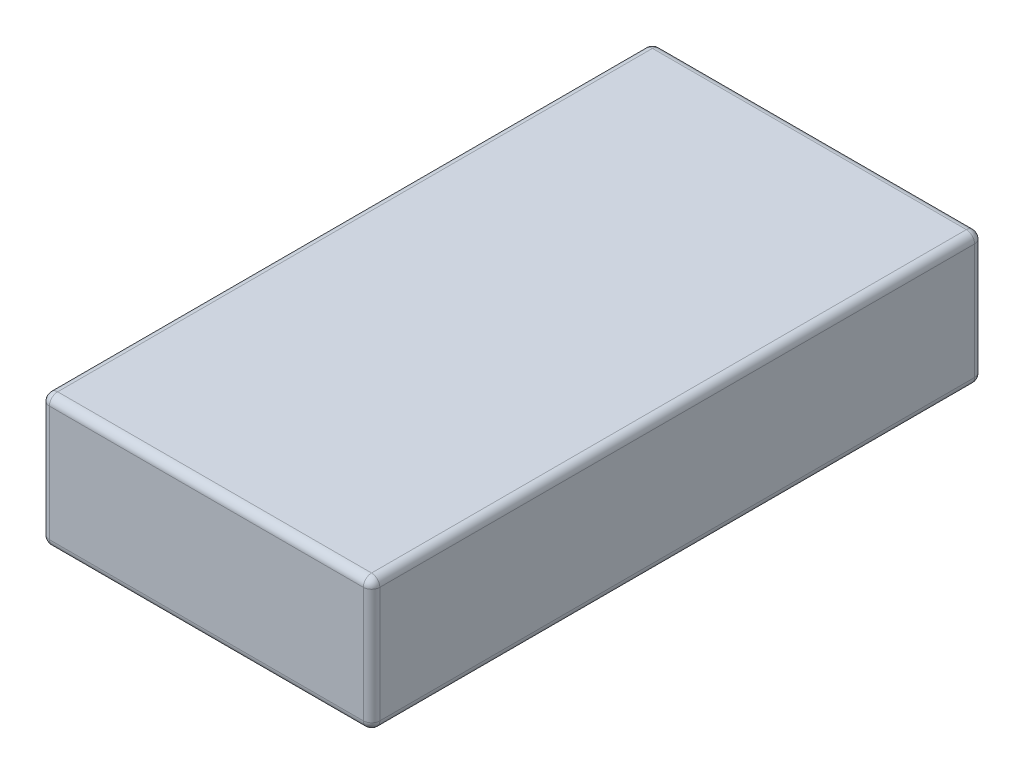
from build123d import *

# Parameters (mm, degrees)
SKETCH1_W           = 20
SKETCH1_H           = 37
BOSS_EXTRUDE1_DEPTH = 8
FILLET1_R           = 0.5


with BuildPart() as part:
    # Sketch1 → Boss-Extrude1 (new body)
    with BuildSketch(Plane(origin=(0, 0, 0), x_dir=(1, 0, 0), z_dir=(0, 1, 0))):
        Rectangle(SKETCH1_W, SKETCH1_H)
    extrude(amount=BOSS_EXTRUDE1_DEPTH)

    # Fillet1
    fillet1_edges = [part.edges().sort_by_distance(p)[0] for p in [
        (-10, 8, 0),
        (0, 8, 18.5),
        (10, 8, 0),
        (0, 0, 18.5),
        (-10, 0, 0),
        (0, 0, -18.5),
        (10, 0, 0),
        (10, 4, 18.5),
        (-10, 4, 18.5),
        (-10, 4, -18.5),
        (10, 4, -18.5),
        (0, 8, -18.5),
    ]]
    fillet(fillet1_edges, radius=FILLET1_R)


solid = part.part
